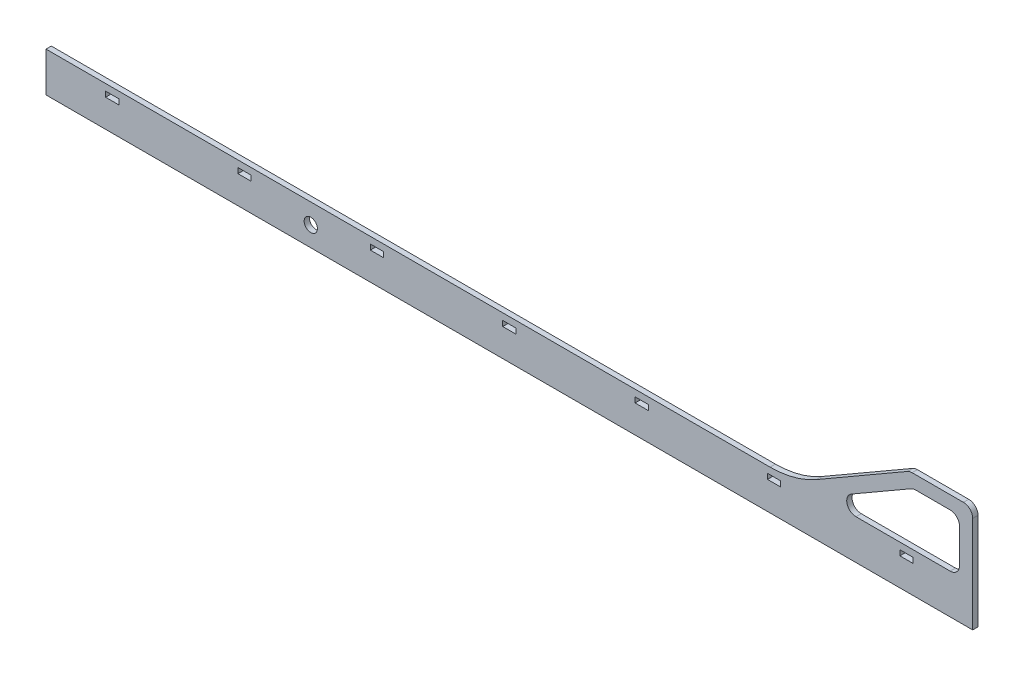
from build123d import *

# Parameters (mm, degrees)
SCHIZZO1_R                   = 5
SCHIZZO1_W                   = 10
SCHIZZO1_H                   = 4
ESTRUSIONE_ESTRUSIONE3_DEPTH = 4


with BuildPart() as part:
    # Schizzo1 → Estrusione-Estrusione3 (new body)
    with BuildSketch(Plane.XY):
        with BuildLine():
            Line((0, 0), (700, 0))
            Line((700, 0), (700, 30))
            Line((700, 30), (700, 73))
            ThreePointArc((700, 73), (697.949747468, 77.949747468), (693, 80))
            Line((693, 80), (654.193736081, 80))
            ThreePointArc((654.193736081, 80), (652.382002765, 79.761480784), (650.693736081, 79.062177826))
            Line((650.693736081, 79.062177826), (581.959107885, 39.378221735))
            ThreePointArc((581.959107885, 39.378221735), (565.076441043, 32.38519216), (546.959107885, 30))
            Line((546.959107885, 30), (0, 30))
            Line((0, 30), (0, 0))
        make_face()
        with Locations((200, 15)):
            Circle(SCHIZZO1_R, mode=Mode.SUBTRACT)
        with Locations((150, 23)):
            Rectangle(SCHIZZO1_W, SCHIZZO1_H, mode=Mode.SUBTRACT)
        with Locations((50, 23)):
            Rectangle(SCHIZZO1_W, SCHIZZO1_H, mode=Mode.SUBTRACT)
        with Locations((250, 23)):
            Rectangle(SCHIZZO1_W, SCHIZZO1_H, mode=Mode.SUBTRACT)
        with Locations((350, 23)):
            Rectangle(SCHIZZO1_W, SCHIZZO1_H, mode=Mode.SUBTRACT)
        with Locations((450, 23)):
            Rectangle(SCHIZZO1_W, SCHIZZO1_H, mode=Mode.SUBTRACT)
        with Locations((550, 23)):
            Rectangle(SCHIZZO1_W, SCHIZZO1_H, mode=Mode.SUBTRACT)
        with Locations((650, 23)):
            Rectangle(SCHIZZO1_W, SCHIZZO1_H, mode=Mode.SUBTRACT)
        with BuildLine():
            Line((690, 63), (690, 37))
            ThreePointArc((690, 37), (687.949747468, 32.050252532), (683, 30))
            Line((683, 30), (611.839907009, 30))
            ThreePointArc((611.839907009, 30), (605.078426225, 35.188266684), (608.339907009, 43.062177826))
            Line((608.339907009, 43.062177826), (653.373228005, 69.062177826))
            ThreePointArc((653.373228005, 69.062177826), (655.06149469, 69.761480784), (656.873228005, 70))
            Line((656.873228005, 70), (683, 70))
            ThreePointArc((683, 70), (687.949747468, 67.949747468), (690, 63))
        make_face(mode=Mode.SUBTRACT)
    extrude(amount=ESTRUSIONE_ESTRUSIONE3_DEPTH)


solid = part.part
